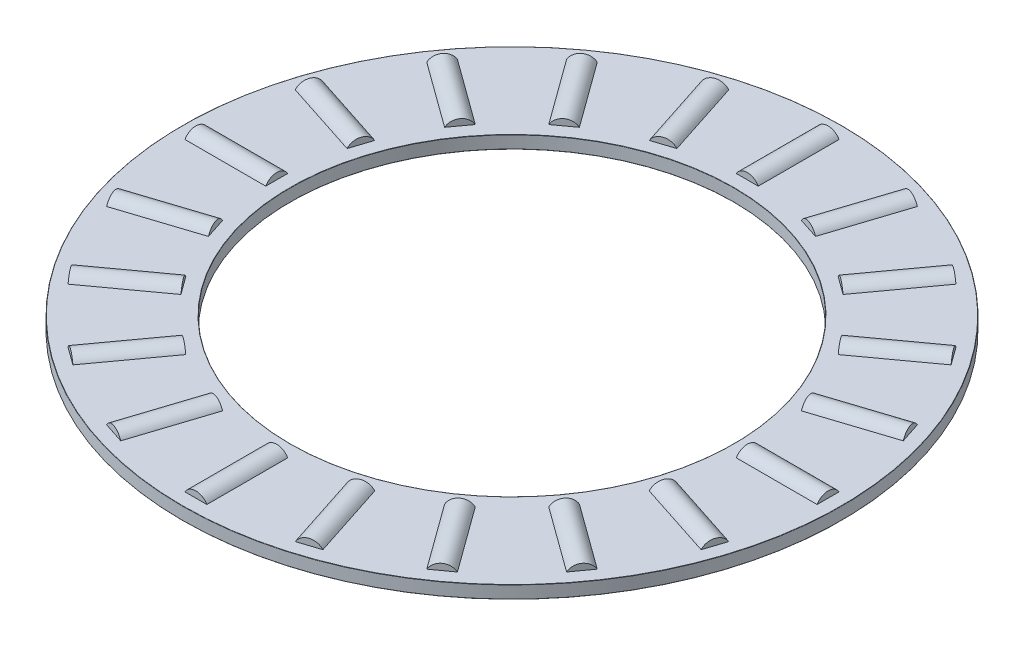
from build123d import *

# Parameters (mm, degrees)
SKETCH1_W         = 8.5
SKETCH1_H         = 1
SKETCH3_W         = 6.375
SKETCH3_H         = 1
SKETCH2_W         = 6.375
SKETCH2_H         = 1
CIRPATTERN1_COUNT = 20
CIRPATTERN1_ANGLE = 342
CIRPATTERN2_COUNT = 20
FILLET2_R         = 0.02


with BuildPart() as part:
    # Sketch1 → Revolve1 (revolve)
    with BuildSketch(Plane(origin=(0, 0, 0), x_dir=(0, 0, -1), z_dir=(1, 0, 0)), mode=Mode.PRIVATE) as revolve1_sk:
        with Locations((-21.75, 0)):
            Rectangle(SKETCH1_W, SKETCH1_H)
    revolve(revolve1_sk.sketch.rotate(Axis((0, -1, 0), (0, 1, 0)), 180), axis=Axis((0, -1, 0), (0, 1, 0)))

    # Sketch3 → Cut-Revolve1 (revolve, cut)
    with BuildSketch(Plane(origin=(0, 0, 0), x_dir=(0, 0, -1), z_dir=(1, 0, 0))):
        with Locations((-21.75, 0.5)):
            Rectangle(SKETCH3_W, SKETCH3_H)
    cut_revolve1 = revolve(axis=Axis((0, 0, 24.9375), (0, 0, -1)), mode=Mode.SUBTRACT)

    # CirPattern2: Cut-Revolve1 ×20 about axis
    cirpattern2_axis = Axis((0, 0, 0), (0, 1, 0))
    for i in range(1, CIRPATTERN2_COUNT):
        add(cut_revolve1.rotate(cirpattern2_axis, i * 360 / CIRPATTERN2_COUNT), mode=Mode.SUBTRACT)

    # Fillet2
    fillet2_edges = [part.edges().sort_by_distance(p)[0] for p in [
        (0, 0.5, 26),
        (0, 0.5, 17.5),
        (0, -0.5, 17.5),
        (0, -0.5, 26),
    ]]
    fillet(fillet2_edges, radius=FILLET2_R)


with BuildPart() as body_2:
    # Sketch2 → Revolve2 (revolve)
    with BuildSketch(Plane(origin=(0, 0, 0), x_dir=(0, 0, -1), z_dir=(1, 0, 0)), mode=Mode.PRIVATE) as revolve2_sk:
        with Locations((-21.75, 0.5)):
            Rectangle(SKETCH2_W, SKETCH2_H)
    revolve(revolve2_sk.sketch.rotate(Axis((0, 0, 24.9375), (0, 0, -1)), 90), axis=Axis((0, 0, 24.9375), (0, 0, -1)))


with BuildPart() as cirpattern1_1:
    # CirPattern1: pattern copy
    add(body_2.part.rotate(Axis((0, 1, 0), (0, -1, 0)), 1 * CIRPATTERN1_ANGLE / (CIRPATTERN1_COUNT - 1)))


with BuildPart() as cirpattern1_2:
    # CirPattern1: pattern copy
    add(body_2.part.rotate(Axis((0, 1, 0), (0, -1, 0)), 2 * CIRPATTERN1_ANGLE / (CIRPATTERN1_COUNT - 1)))


with BuildPart() as cirpattern1_3:
    # CirPattern1: pattern copy
    add(body_2.part.rotate(Axis((0, 1, 0), (0, -1, 0)), 3 * CIRPATTERN1_ANGLE / (CIRPATTERN1_COUNT - 1)))


with BuildPart() as cirpattern1_4:
    # CirPattern1: pattern copy
    add(body_2.part.rotate(Axis((0, 1, 0), (0, -1, 0)), 4 * CIRPATTERN1_ANGLE / (CIRPATTERN1_COUNT - 1)))


with BuildPart() as cirpattern1_5:
    # CirPattern1: pattern copy
    add(body_2.part.rotate(Axis((0, 1, 0), (0, -1, 0)), 5 * CIRPATTERN1_ANGLE / (CIRPATTERN1_COUNT - 1)))


with BuildPart() as cirpattern1_6:
    # CirPattern1: pattern copy
    add(body_2.part.rotate(Axis((0, 1, 0), (0, -1, 0)), 6 * CIRPATTERN1_ANGLE / (CIRPATTERN1_COUNT - 1)))


with BuildPart() as cirpattern1_7:
    # CirPattern1: pattern copy
    add(body_2.part.rotate(Axis((0, 1, 0), (0, -1, 0)), 7 * CIRPATTERN1_ANGLE / (CIRPATTERN1_COUNT - 1)))


with BuildPart() as cirpattern1_8:
    # CirPattern1: pattern copy
    add(body_2.part.rotate(Axis((0, 1, 0), (0, -1, 0)), 8 * CIRPATTERN1_ANGLE / (CIRPATTERN1_COUNT - 1)))


with BuildPart() as cirpattern1_9:
    # CirPattern1: pattern copy
    add(body_2.part.rotate(Axis((0, 1, 0), (0, -1, 0)), 9 * CIRPATTERN1_ANGLE / (CIRPATTERN1_COUNT - 1)))


with BuildPart() as cirpattern1_10:
    # CirPattern1: pattern copy
    add(body_2.part.rotate(Axis((0, 1, 0), (0, -1, 0)), 10 * CIRPATTERN1_ANGLE / (CIRPATTERN1_COUNT - 1)))


with BuildPart() as cirpattern1_11:
    # CirPattern1: pattern copy
    add(body_2.part.rotate(Axis((0, 1, 0), (0, -1, 0)), 11 * CIRPATTERN1_ANGLE / (CIRPATTERN1_COUNT - 1)))


with BuildPart() as cirpattern1_12:
    # CirPattern1: pattern copy
    add(body_2.part.rotate(Axis((0, 1, 0), (0, -1, 0)), 12 * CIRPATTERN1_ANGLE / (CIRPATTERN1_COUNT - 1)))


with BuildPart() as cirpattern1_13:
    # CirPattern1: pattern copy
    add(body_2.part.rotate(Axis((0, 1, 0), (0, -1, 0)), 13 * CIRPATTERN1_ANGLE / (CIRPATTERN1_COUNT - 1)))


with BuildPart() as cirpattern1_14:
    # CirPattern1: pattern copy
    add(body_2.part.rotate(Axis((0, 1, 0), (0, -1, 0)), 14 * CIRPATTERN1_ANGLE / (CIRPATTERN1_COUNT - 1)))


with BuildPart() as cirpattern1_15:
    # CirPattern1: pattern copy
    add(body_2.part.rotate(Axis((0, 1, 0), (0, -1, 0)), 15 * CIRPATTERN1_ANGLE / (CIRPATTERN1_COUNT - 1)))


with BuildPart() as cirpattern1_16:
    # CirPattern1: pattern copy
    add(body_2.part.rotate(Axis((0, 1, 0), (0, -1, 0)), 16 * CIRPATTERN1_ANGLE / (CIRPATTERN1_COUNT - 1)))


with BuildPart() as cirpattern1_17:
    # CirPattern1: pattern copy
    add(body_2.part.rotate(Axis((0, 1, 0), (0, -1, 0)), 17 * CIRPATTERN1_ANGLE / (CIRPATTERN1_COUNT - 1)))


with BuildPart() as cirpattern1_18:
    # CirPattern1: pattern copy
    add(body_2.part.rotate(Axis((0, 1, 0), (0, -1, 0)), 18 * CIRPATTERN1_ANGLE / (CIRPATTERN1_COUNT - 1)))


with BuildPart() as cirpattern1_19:
    # CirPattern1: pattern copy
    add(body_2.part.rotate(Axis((0, 1, 0), (0, -1, 0)), 19 * CIRPATTERN1_ANGLE / (CIRPATTERN1_COUNT - 1)))


solid = Compound([part.part, body_2.part, cirpattern1_1.part, cirpattern1_2.part, cirpattern1_3.part, cirpattern1_4.part, cirpattern1_5.part, cirpattern1_6.part, cirpattern1_7.part, cirpattern1_8.part, cirpattern1_9.part, cirpattern1_10.part, cirpattern1_11.part, cirpattern1_12.part, cirpattern1_13.part, cirpattern1_14.part, cirpattern1_15.part, cirpattern1_16.part, cirpattern1_17.part, cirpattern1_18.part, cirpattern1_19.part])
